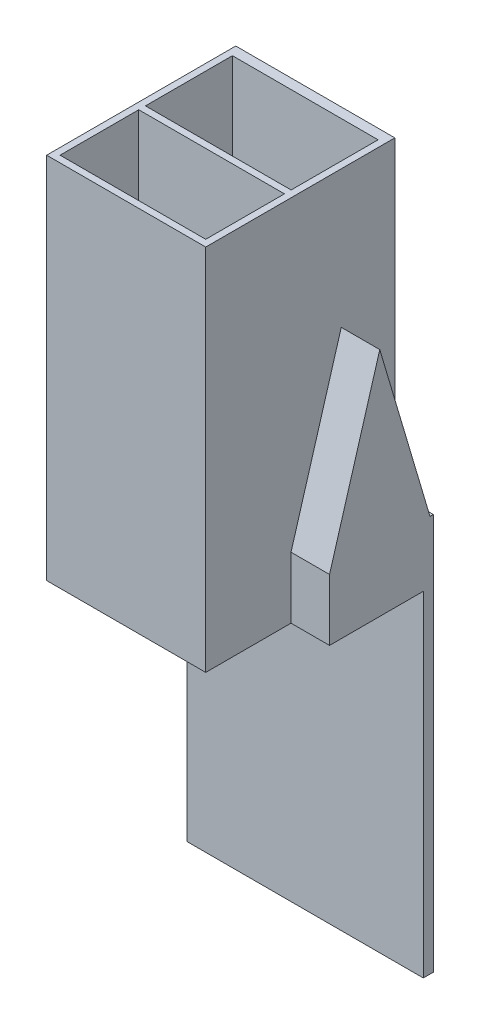
from build123d import *

# Parameters (mm, degrees)
SKIZZE1_W                       = 9.5
SKIZZE1_H                       = 11.093
SKIZZE1_W_2                     = 8.7
SKIZZE1_H_2                     = 4.7
SKIZZE1_H_3                     = 5.193
AUFSATZ_LINEAR_AUSTRAGEN1_DEPTH = 22
AUFSATZ_LINEAR_AUSTRAGEN2_DEPTH = 2.3
SCHNITT_LINEAR_AUSTRAGEN1_DEPTH = 13.7
SKIZZE4_W                       = 13.3
SKIZZE4_H                       = 5.193
SCHNITT_LINEAR_AUSTRAGEN2_DEPTH = 0.4
SKIZZE5_W                       = 14.1
SKIZZE5_H                       = 0.4
AUFSATZ_LINEAR_AUSTRAGEN3_DEPTH = 20
AUFSATZ_LINEAR_AUSTRAGEN4_DEPTH = 0.2


with BuildPart() as part:
    # Skizze1 → Aufsatz-Linear austragen1 (new body)
    with BuildSketch(Plane(origin=(0, 0, 0), x_dir=(1, 0, 0), z_dir=(0, 1, 0))):
        with Locations((4.75, 5.5465)):
            Rectangle(SKIZZE1_W, SKIZZE1_H)
        with Locations((4.75, 2.75)):
            Rectangle(SKIZZE1_W_2, SKIZZE1_H_2, mode=Mode.SUBTRACT)
        with Locations((4.75, 8.0965)):
            Rectangle(SKIZZE1_W_2, SKIZZE1_H_3, mode=Mode.SUBTRACT)
    extrude(amount=AUFSATZ_LINEAR_AUSTRAGEN1_DEPTH)

    # Skizze2 → Aufsatz-Linear austragen2 (add)
    with BuildSketch(Plane.ZY):
        Polygon((-11.093, 0), (-11.093, 3.67), (-8.093, 13.8), (-5.093, 3.67), (-5.093, 0), align=None)
    aufsatz_linear_austragen2 = extrude(amount=AUFSATZ_LINEAR_AUSTRAGEN2_DEPTH)

    # Spiegeln1: Aufsatz-Linear austragen2 across plane
    add(aufsatz_linear_austragen2.mirror(Plane(origin=(4.75, 0, 0), x_dir=(0, 0, 1), z_dir=(1, 0, 0))))

    # Skizze3 → Schnitt-Linear austragen1 (cut)
    with BuildSketch(Plane.ZY.offset(2.3)):
        Polygon((-10.693, 0.4), (-5.493, 0.4), (-5.493, 3.612014671), (-8.093, 12.391348004), (-10.693, 3.612014671), align=None)
    extrude(amount=-SCHNITT_LINEAR_AUSTRAGEN1_DEPTH, mode=Mode.SUBTRACT)

    # Skizze4 → Schnitt-Linear austragen2 (cut)
    with BuildSketch(Plane.XZ):
        with Locations((4.75, -8.0965)):
            Rectangle(SKIZZE4_W, SKIZZE4_H)
    extrude(amount=-SCHNITT_LINEAR_AUSTRAGEN2_DEPTH, mode=Mode.SUBTRACT)

    # Skizze5 → Aufsatz-Linear austragen3 (add)
    with BuildSketch(Plane.XZ):
        with Locations((4.75, -10.893)):
            Rectangle(SKIZZE5_W, SKIZZE5_H)
    extrude(amount=AUFSATZ_LINEAR_AUSTRAGEN3_DEPTH)

    # Skizze6 → Aufsatz-Linear austragen4 (add)
    with BuildSketch(Plane(origin=(0, 0, -11.093), x_dir=(-1, 0, 0), z_dir=(0, 0, -1))):
        Polygon((0, 3.67), (2.3, 3.67), (2.3, -20), (-11.8, -20), (-11.8, 3.67), (-9.5, 3.67), (-9.5, 22), (0, 22), align=None)
    extrude(amount=AUFSATZ_LINEAR_AUSTRAGEN4_DEPTH)


solid = part.part
